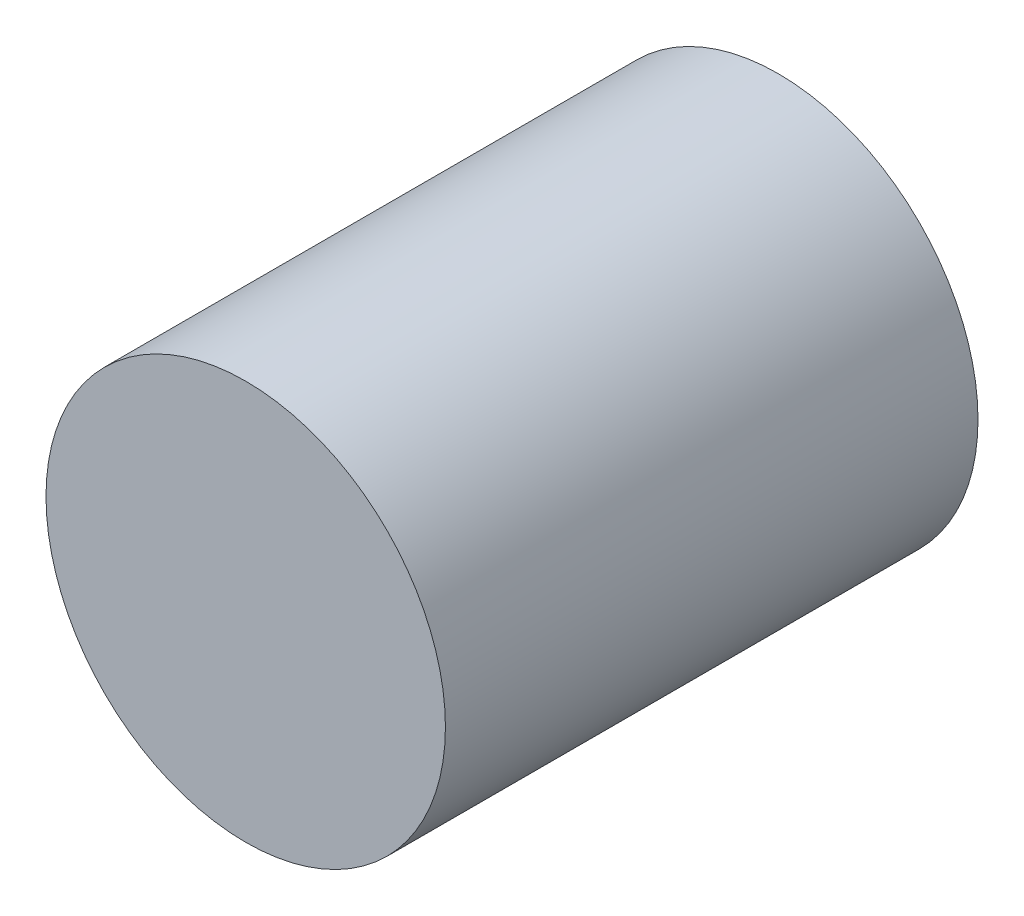
from build123d import *

# Parameters (mm, degrees)
SKETCH_1_R      = 1.5
EXTRUDE_1_DEPTH = 4


with BuildPart() as part:
    # 草图1 → 凸台-拉伸1 (new body)
    with BuildSketch(Plane.XY):
        Circle(SKETCH_1_R)
    extrude(amount=EXTRUDE_1_DEPTH)


solid = part.part
